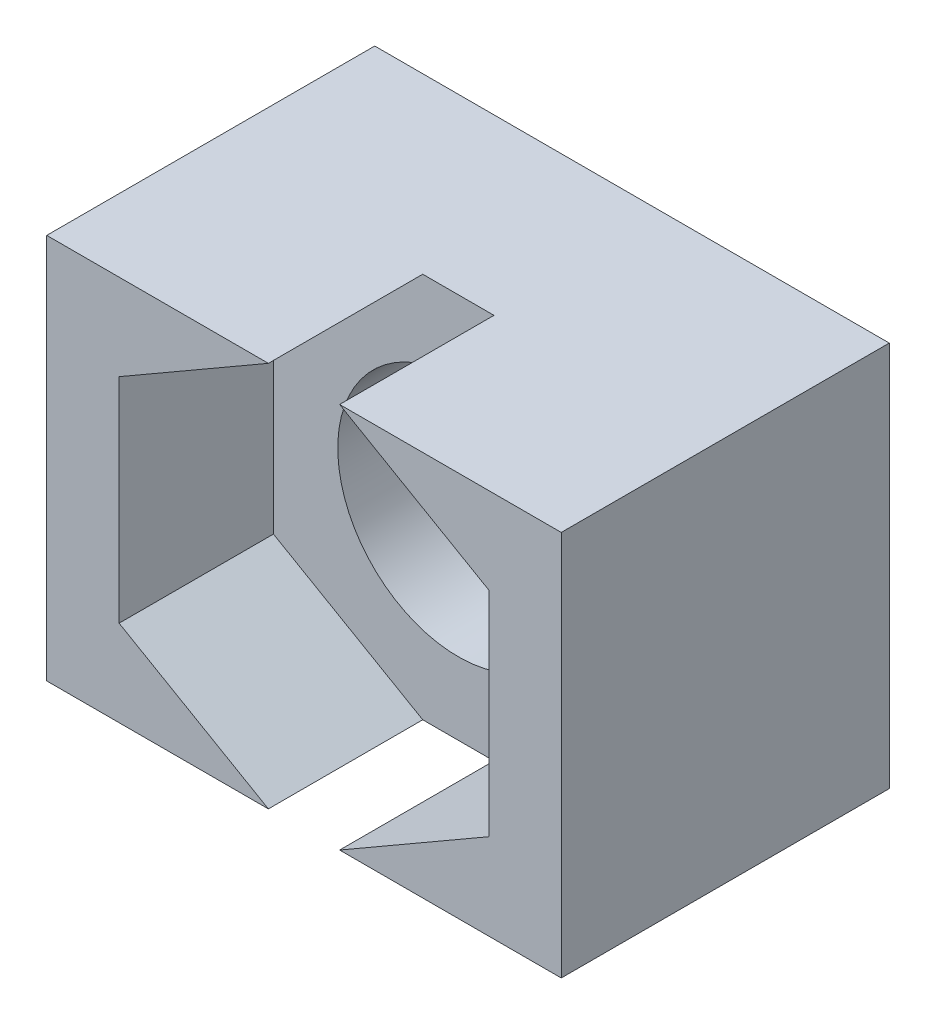
from build123d import *

# Parameters (mm, degrees)
ESBO_O1_W                = 8
ESBO_O1_H                = 6
RESSALTO_EXTRUS_O1_DEPTH = 5.1
CORTE_EXTRUS_O1_DEPTH    = 2.4
ESBO_O3_R                = 1.875
CORTE_EXTRUS_O2_DEPTH    = 2.7


with BuildPart() as part:
    # Esboço1 → Ressalto-extrusão1 (new body)
    with BuildSketch(Plane.XY):
        Rectangle(ESBO_O1_W, ESBO_O1_H)
    extrude(amount=RESSALTO_EXTRUS_O1_DEPTH)

    # Esboço2 → Corte-extrusão1 (cut)
    with BuildSketch(Plane.XY.offset(5.1)):
        Polygon((0, -3.319764048), (2.875, -1.659882024), (2.875, 1.659882024), (0, 3.319764048), (-2.875, 1.659882024), (-2.875, -1.659882024), align=None)
    extrude(amount=-CORTE_EXTRUS_O1_DEPTH, mode=Mode.SUBTRACT)

    # Esboço3 → Corte-extrusão2 (cut)
    with BuildSketch(Plane.XY.offset(2.7)):
        Circle(ESBO_O3_R)
    extrude(amount=-CORTE_EXTRUS_O2_DEPTH, mode=Mode.SUBTRACT)


solid = part.part
